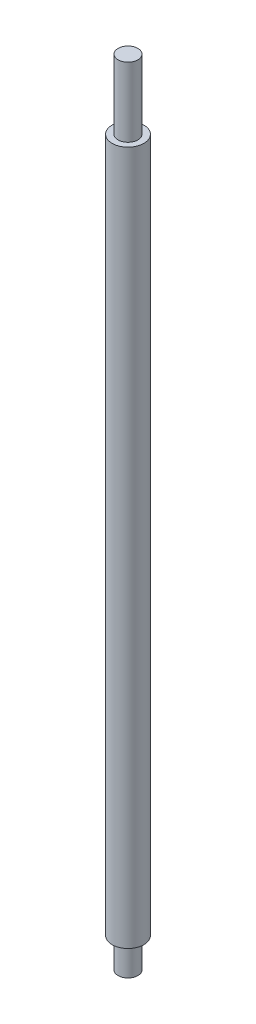
from build123d import *

# Parameters (mm, degrees)
SKETCH1_R           = 8
BOSS_EXTRUDE1_DEPTH = 350
SKETCH2_R           = 5
BOSS_EXTRUDE2_DEPTH = 35
SKETCH3_R           = 5
BOSS_EXTRUDE3_DEPTH = 15


with BuildPart() as part:
    # Sketch1 → Boss-Extrude1 (new body)
    with BuildSketch(Plane(origin=(0, 0, 0), x_dir=(1, 0, 0), z_dir=(0, 1, 0))):
        Circle(SKETCH1_R)
    extrude(amount=BOSS_EXTRUDE1_DEPTH)

    # Sketch2 → Boss-Extrude2 (add)
    with BuildSketch(Plane(origin=(0, 350, 0), x_dir=(1, 0, 0), z_dir=(0, 1, 0))):
        Circle(SKETCH2_R)
    extrude(amount=BOSS_EXTRUDE2_DEPTH)

    # Sketch3 → Boss-Extrude3 (add)
    with BuildSketch(Plane.XZ):
        Circle(SKETCH3_R)
    extrude(amount=BOSS_EXTRUDE3_DEPTH)


solid = part.part
